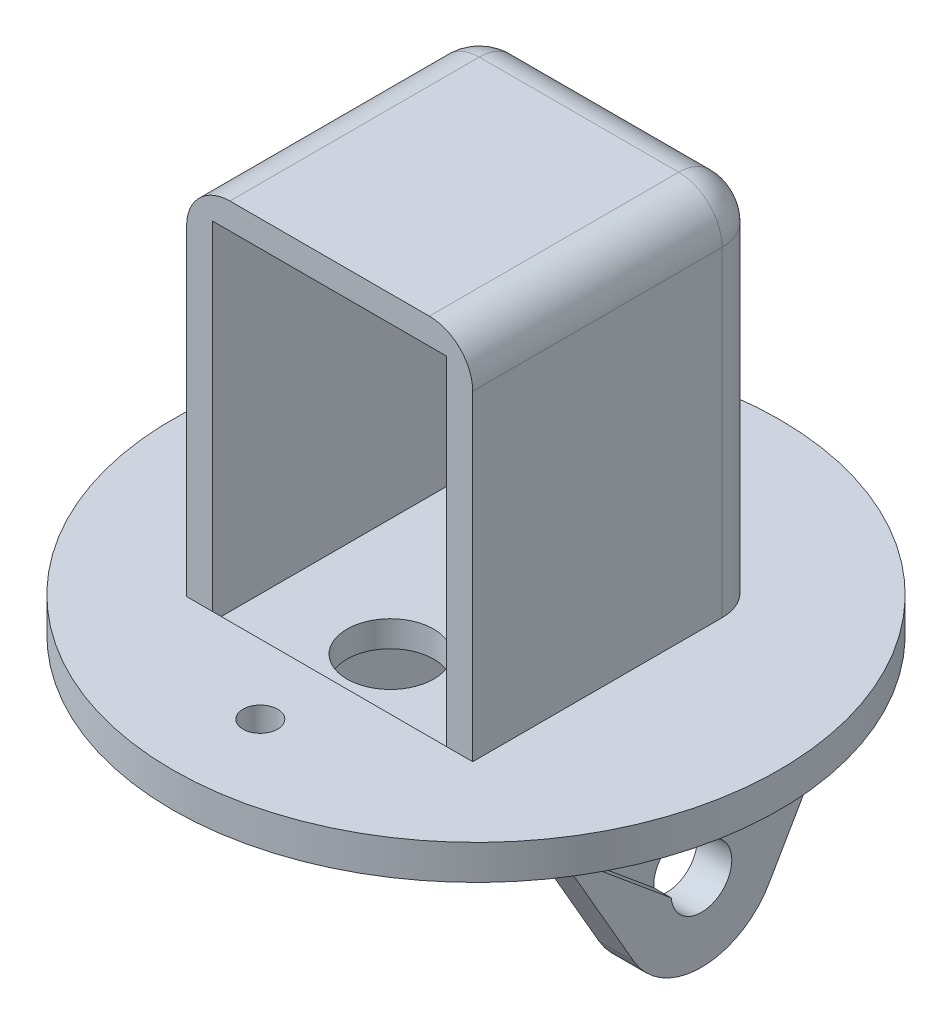
from build123d import *

# Parameters (mm, degrees)
SKETCH_1_R          = 9
SKETCH_1_R_2        = 2.5
EXTRUDE_1_DEPTH     = 4
EXTRUDE_2_DEPTH     = 4
SKETCH_6_W          = 33.754755736
SKETCH_6_H          = 3
EXTRUDE_5_DEPTH     = 52
SKETCH_7_R          = 2.5
EXTRUDE_6_DEPTH     = 4
SKETCH_8_R          = 2.5
EXTRUDE_7_DEPTH     = 8
SKETCH_9_W          = 27
SKETCH_9_H          = 3
EXTRUDE_8_DEPTH     = 40
SKETCH_10_W         = 8
SKETCH_10_H         = 8
CUT_EXTRUDE_1_DEPTH = 40
SKETCH_11_W         = 27
SKETCH_11_H         = 30.754755736
EXTRUDE_9_DEPTH     = 3
SKETCH_12_R         = 35
SKETCH_12_W         = 33
SKETCH_12_H         = 33.754755736
EXTRUDE_10_DEPTH    = 4
SKETCH_13_R         = 2
CUT_EXTRUDE_2_DEPTH = 4
FILLET_1_R          = 5
SKETCH_14_R         = 5
CUT_EXTRUDE_3_DEPTH = 3
CUT_EXTRUDE_4_DEPTH = 2
SKETCH_16_R         = 3.5
CUT_EXTRUDE_5_DEPTH = 6


with BuildPart() as part:
    # 草图1 → 凸台-拉伸1 (new body)
    with BuildSketch(Plane(origin=(0, 0, 0), x_dir=(0, 0, -1), z_dir=(1, 0, 0))):
        Circle(SKETCH_1_R)
        Circle(SKETCH_1_R_2, mode=Mode.SUBTRACT)
    extrude(amount=-EXTRUDE_1_DEPTH)

    # 草图2 → 凸台-拉伸2 (add)
    with BuildSketch(Plane(origin=(0, 0, 0), x_dir=(0, 0, -1), z_dir=(1, 0, 0))):
        with BuildLine():
            Line((-16.878750928, 11.234854176), (-7.794228634, -4.5))
            ThreePointArc((-7.794228634, -4.5), (-2.329371406, 8.693332437), (9, 0))
            ThreePointArc((9, 0), (8.719533008, -2.229292291), (7.895612418, -4.319641714))
            Line((7.895612418, -4.319641714), (16.876004808, 11.234854176))
            Line((16.876004808, 11.234854176), (-16.878750928, 11.234854176))
        make_face()
    extrude(amount=-EXTRUDE_2_DEPTH)

    # 草图6 → 凸台-拉伸5 (add)
    with BuildSketch(Plane(origin=(0, 0, 0), x_dir=(0, 0, -1), z_dir=(1, 0, 0))):
        with Locations((-0.00137306, 12.734854176)):
            Rectangle(SKETCH_6_W, SKETCH_6_H)
    extrude(amount=-EXTRUDE_5_DEPTH)

    # 草图7 → 凸台-拉伸6 (add)
    with BuildSketch(Plane(origin=(-35.5, 0, 0), x_dir=(0, 0, -1), z_dir=(1, 0, 0))):
        with BuildLine():
            Line((-16.878750928, 11.234854176), (-7.794228634, -4.5))
            ThreePointArc((-7.794228634, -4.5), (0.103450209, -8.999405428), (7.895612418, -4.319641714))
            Line((7.895612418, -4.319641714), (16.876004808, 11.234854176))
            Line((16.876004808, 11.234854176), (-16.878750928, 11.234854176))
        make_face()
        Circle(SKETCH_7_R, mode=Mode.SUBTRACT)
    extrude(amount=-EXTRUDE_6_DEPTH)

    # 草图8 → 凸台-拉伸7 (add)
    with BuildSketch(Plane(origin=(-35.5, 0, 0), x_dir=(0, 0, -1), z_dir=(1, 0, 0))):
        Circle(SKETCH_8_R)
    extrude(amount=-EXTRUDE_7_DEPTH)

    # 草图9 → 凸台-拉伸8 (add)
    with BuildSketch(Plane(origin=(0, 14.234854176, 0), x_dir=(1, 0, 0), z_dir=(0, 1, 0))):
        Polygon((-12.5, 16.876004808), (-12.5, 13.876004808), (-12.5, -16.878750928), (-9.5, -16.878750928), (-9.5, 16.876004808), align=None)
        Polygon((-39.5, -16.878750928), (-39.5, 13.876004808), (-39.5, 16.876004808), (-42.5, 16.876004808), (-42.5, -16.878750928), align=None)
        with Locations((-26, 15.376004808)):
            Rectangle(SKETCH_9_W, SKETCH_9_H)
    extrude(amount=EXTRUDE_8_DEPTH)

    # 草图10 → 切除-拉伸1 (cut)
    with BuildSketch(Plane.XY.offset(-13.876004808)):
        with Locations((-26, 46.234854176)):
            Rectangle(SKETCH_10_W, SKETCH_10_H)
    extrude(amount=-CUT_EXTRUDE_1_DEPTH, mode=Mode.SUBTRACT)

    # 草图11 → 凸台-拉伸9 (add)
    with BuildSketch(Plane(origin=(0, 54.234854176, 0), x_dir=(1, 0, 0), z_dir=(0, 1, 0))):
        Polygon((-9.5, -16.878750928), (-9.5, 16.876004808), (-42.5, 16.876004808), (-42.5, -16.878750928), (-39.5, -16.878750928), (-39.5, 13.876004808), (-12.5, 13.876004808), (-12.5, -16.878750928), align=None)
        with Locations((-26, -1.50137306)):
            Rectangle(SKETCH_11_W, SKETCH_11_H)
    extrude(amount=EXTRUDE_9_DEPTH)

    # 草图12 → 凸台-拉伸10 (add)
    with BuildSketch(Plane.XZ.offset(-11.234854176)):
        with Locations((-26, 0.00137306)):
            Circle(SKETCH_12_R)
        with Locations((-26, 0.00137306)):
            Rectangle(SKETCH_12_W, SKETCH_12_H, mode=Mode.SUBTRACT)
    extrude(amount=-EXTRUDE_10_DEPTH)

    # 草图13 → 切除-拉伸2 (cut)
    with BuildSketch(Plane(origin=(0, 15.234854176, 0), x_dir=(1, 0, 0), z_dir=(0, 1, 0))):
        with Locations((-26, -24.878750928)):
            Circle(SKETCH_13_R)
    extrude(amount=-CUT_EXTRUDE_2_DEPTH, mode=Mode.SUBTRACT)

    # 圆角1
    fillet_1_edges = [part.edges().sort_by_distance(p)[0] for p in [
        (-9.5, 57.234854176, 0.00137306),
        (-26, 57.234854176, -16.876004808),
        (-42.5, 57.234854176, 0.00137306),
        (-9.5, 36.234854176, -16.876004808),
        (-42.5, 36.234854176, -16.876004808),
    ]]
    fillet(fillet_1_edges, radius=FILLET_1_R)

    # 草图14 → 切除-拉伸3 (cut)
    with BuildSketch(Plane(origin=(0, 14.234854176, 0), x_dir=(1, 0, 0), z_dir=(0, 1, 0))):
        with Locations((-26, -9.878750928)):
            Circle(SKETCH_14_R)
    extrude(amount=-CUT_EXTRUDE_3_DEPTH, mode=Mode.SUBTRACT)

    # 草图15 → 切除-拉伸4 (cut)
    with BuildSketch(Plane(origin=(0, 0, 0), x_dir=(0, 0, -1), z_dir=(1, 0, 0))):
        with BuildLine():
            ThreePointArc((-3.486194042, -0.310565776), (-2.801542224, 2.097942126), (-0.683036299, 3.432704679))
            Line((-0.683036299, 3.432704679), (-10.750051286, 10.010751226))
            ThreePointArc((-10.750051286, 10.010751226), (-12.980710136, 9.609748083), (-12.708559077, 7.359731144))
            Line((-12.708559077, 7.359731144), (-3.486194042, -0.310565776))
        make_face()
    extrude(amount=-CUT_EXTRUDE_4_DEPTH, mode=Mode.SUBTRACT)

    # 草图16 → 切除-拉伸5 (cut)
    with BuildSketch(Plane(origin=(0, 0, 0), x_dir=(0, 0, -1), z_dir=(1, 0, 0))):
        Circle(SKETCH_16_R)
    extrude(amount=-CUT_EXTRUDE_5_DEPTH, mode=Mode.SUBTRACT)


solid = part.part
